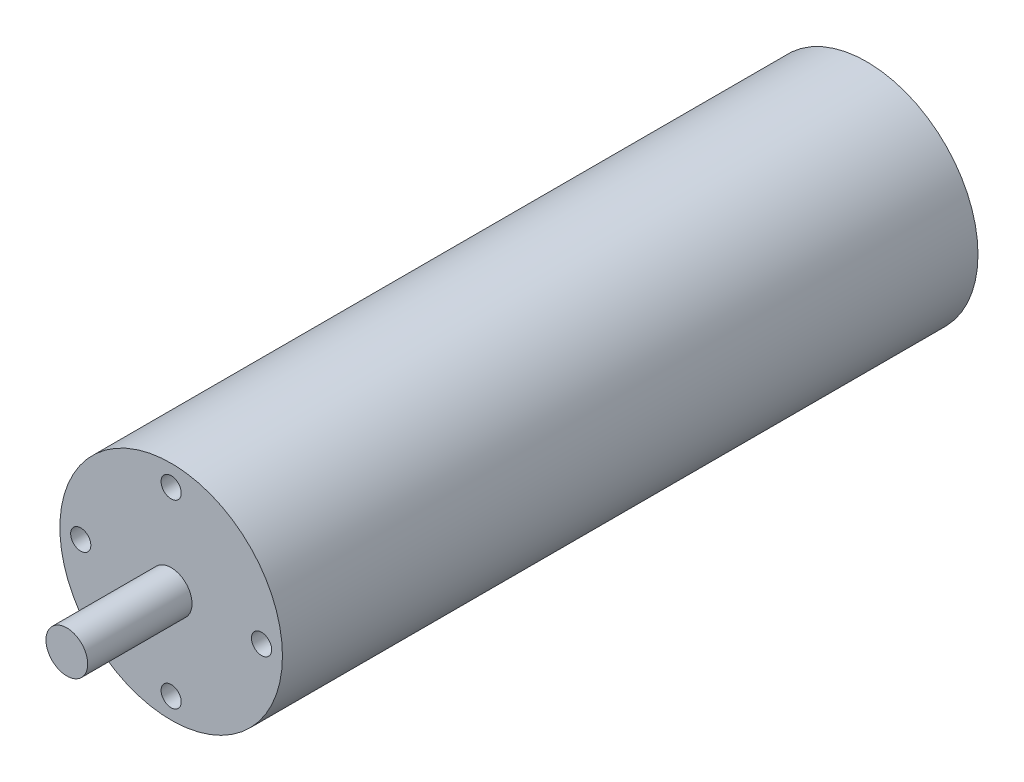
from build123d import *

# Parameters (mm, degrees)
SKETCH1_R           = 16
BOSS_EXTRUDE1_DEPTH = 100
SKETCH2_R           = 3
BOSS_EXTRUDE2_DEPTH = 15
CIRPATTERN1_COUNT   = 4


with BuildPart() as part:
    # Sketch1 → Boss-Extrude1 (new body)
    with BuildSketch(Plane.XY):
        Circle(SKETCH1_R)
    extrude(amount=BOSS_EXTRUDE1_DEPTH)

    # Sketch2 → Boss-Extrude2 (add)
    with BuildSketch(Plane.XY.offset(100)):
        Circle(SKETCH2_R)
    extrude(amount=BOSS_EXTRUDE2_DEPTH)

    # Sketch6 → M3.5x0.6 Tapped Hole1 (revolve, cut)
    with BuildSketch(Plane(origin=(0, 13, 100), x_dir=(0, -1, 0), z_dir=(1, 0, 0))):
        Polygon((0, 0), (0, 9.761247898), (1.45, 8.89), (1.45, 0), align=None)
    m3_5x0_6_tapped_hole1 = revolve(axis=Axis((0, 13, 106.35), (0, 0, -1)), mode=Mode.SUBTRACT)

    # CirPattern1: M3.5x0.6 Tapped Hole1 ×4 about axis
    cirpattern1_axis = Axis((0, 0, 0), (0, 0, 1))
    for i in range(1, CIRPATTERN1_COUNT):
        add(m3_5x0_6_tapped_hole1.rotate(cirpattern1_axis, i * 360 / CIRPATTERN1_COUNT), mode=Mode.SUBTRACT)


solid = part.part
